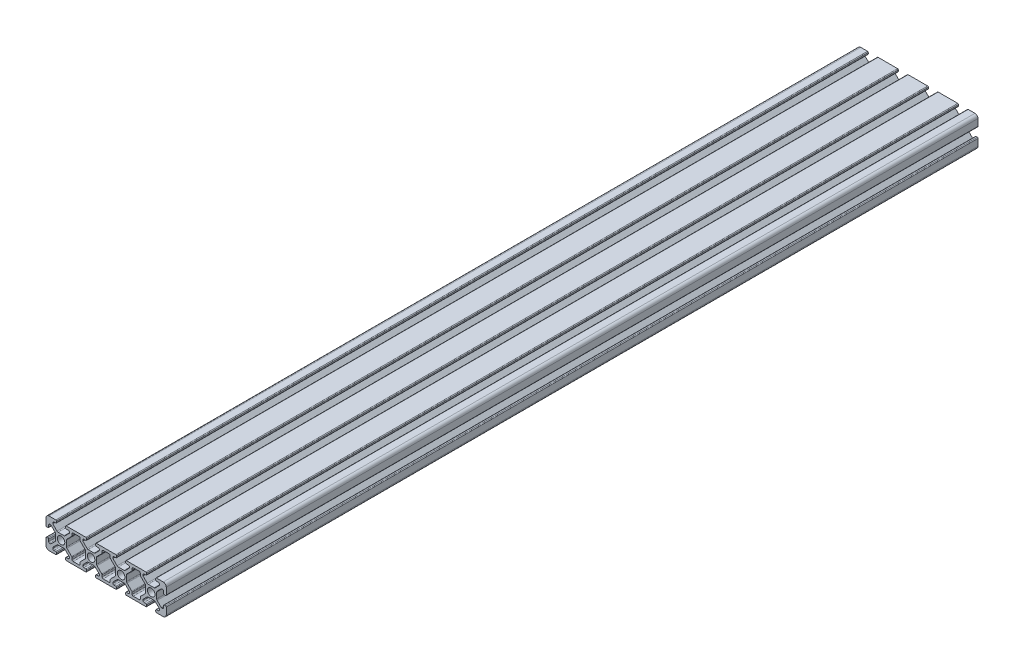
from build123d import *

# Parameters (mm, degrees)
SKETCH1_R           = 2.5
BOSS_EXTRUDE1_DEPTH = 270


with BuildPart() as part:
    # Sketch1 → Boss-Extrude1 (new body, symmetric)
    with BuildSketch(Plane.XY):
        with BuildLine():
            Line((2, 0), (6.5, 0))
            ThreePointArc((6.5, 0), (6.853553391, 0.146446609), (7, 0.5))
            Line((7, 0.5), (7, 1.3))
            ThreePointArc((7, 1.3), (6.853553391, 1.653553391), (6.5, 1.8))
            Line((6.5, 1.8), (5.25, 1.8))
            ThreePointArc((5.25, 1.8), (4.719669914, 2.019669914), (4.5, 2.55))
            Line((4.5, 2.55), (4.5, 3.227207794))
            Line((4.5, 3.227207794), (7.329898987, 6.057106781))
            ThreePointArc((7.329898987, 6.057106781), (7.654322336, 6.273879533), (8.037005769, 6.35))
            Line((8.037005769, 6.35), (11.962994231, 6.35))
            ThreePointArc((11.962994231, 6.35), (12.345677664, 6.273879533), (12.670101013, 6.057106781))
            Line((12.670101013, 6.057106781), (15.5, 3.227207794))
            Line((15.5, 3.227207794), (15.5, 2.55))
            ThreePointArc((15.5, 2.55), (15.280330086, 2.019669914), (14.75, 1.8))
            Line((14.75, 1.8), (13.5, 1.8))
            ThreePointArc((13.5, 1.8), (13.146446609, 1.653553391), (13, 1.3))
            Line((13, 1.3), (13, 0.5))
            ThreePointArc((13, 0.5), (13.146446609, 0.146446609), (13.5, 0))
            Line((13.5, 0), (26.5, 0))
            ThreePointArc((26.5, 0), (26.853553391, 0.146446609), (27, 0.5))
            Line((27, 0.5), (27, 1.3))
            ThreePointArc((27, 1.3), (26.853553391, 1.653553391), (26.5, 1.8))
            Line((26.5, 1.8), (25.25, 1.8))
            ThreePointArc((25.25, 1.8), (24.719669914, 2.019669914), (24.5, 2.55))
            Line((24.5, 2.55), (24.5, 3.227207794))
            Line((24.5, 3.227207794), (27.329898987, 6.057106781))
            ThreePointArc((27.329898987, 6.057106781), (27.654322336, 6.273879533), (28.037005769, 6.35))
            Line((28.037005769, 6.35), (31.962994231, 6.35))
            ThreePointArc((31.962994231, 6.35), (32.345677664, 6.273879533), (32.670101013, 6.057106781))
            Line((32.670101013, 6.057106781), (35.5, 3.227207794))
            Line((35.5, 3.227207794), (35.5, 2.55))
            ThreePointArc((35.5, 2.55), (35.280330086, 2.019669914), (34.75, 1.8))
            Line((34.75, 1.8), (33.5, 1.8))
            ThreePointArc((33.5, 1.8), (33.146446609, 1.653553391), (33, 1.3))
            Line((33, 1.3), (33, 0.5))
            ThreePointArc((33, 0.5), (33.146446609, 0.146446609), (33.5, 0))
            Line((33.5, 0), (46.5, 0))
            ThreePointArc((46.5, 0), (46.853553391, 0.146446609), (47, 0.5))
            Line((47, 0.5), (47, 1.3))
            ThreePointArc((47, 1.3), (46.853553391, 1.653553391), (46.5, 1.8))
            Line((46.5, 1.8), (45.25, 1.8))
            ThreePointArc((45.25, 1.8), (44.719669914, 2.019669914), (44.5, 2.55))
            Line((44.5, 2.55), (44.5, 3.227207794))
            Line((44.5, 3.227207794), (47.329898987, 6.057106781))
            ThreePointArc((47.329898987, 6.057106781), (47.654322336, 6.273879533), (48.037005769, 6.35))
            Line((48.037005769, 6.35), (51.962994231, 6.35))
            ThreePointArc((51.962994231, 6.35), (52.345677664, 6.273879533), (52.670101013, 6.057106781))
            Line((52.670101013, 6.057106781), (55.5, 3.227207794))
            Line((55.5, 3.227207794), (55.5, 2.55))
            ThreePointArc((55.5, 2.55), (55.280330086, 2.019669914), (54.75, 1.8))
            Line((54.75, 1.8), (53.5, 1.8))
            ThreePointArc((53.5, 1.8), (53.146446609, 1.653553391), (53, 1.3))
            Line((53, 1.3), (53, 0.5))
            ThreePointArc((53, 0.5), (53.146446609, 0.146446609), (53.5, 0))
            Line((53.5, 0), (66.5, 0))
            ThreePointArc((66.5, 0), (66.853553391, 0.146446609), (67, 0.5))
            Line((67, 0.5), (67, 1.3))
            ThreePointArc((67, 1.3), (66.853553391, 1.653553391), (66.5, 1.8))
            Line((66.5, 1.8), (65.25, 1.8))
            ThreePointArc((65.25, 1.8), (64.719669914, 2.019669914), (64.5, 2.55))
            Line((64.5, 2.55), (64.5, 3.227207794))
            Line((64.5, 3.227207794), (67.329898987, 6.057106781))
            ThreePointArc((67.329898987, 6.057106781), (67.654322336, 6.273879533), (68.037005769, 6.35))
            Line((68.037005769, 6.35), (71.962994231, 6.35))
            ThreePointArc((71.962994231, 6.35), (72.345677664, 6.273879533), (72.670101013, 6.057106781))
            Line((72.670101013, 6.057106781), (75.5, 3.227207794))
            Line((75.5, 3.227207794), (75.5, 2.55))
            ThreePointArc((75.5, 2.55), (75.280330086, 2.019669914), (74.75, 1.8))
            Line((74.75, 1.8), (73.5, 1.8))
            ThreePointArc((73.5, 1.8), (73.146446609, 1.653553391), (73, 1.3))
            Line((73, 1.3), (73, 0.5))
            ThreePointArc((73, 0.5), (73.146446609, 0.146446609), (73.5, 0))
            Line((73.5, 0), (78, 0))
            ThreePointArc((78, 0), (79.414213562, 0.585786438), (80, 2))
            Line((80, 2), (80, 6.5))
            ThreePointArc((80, 6.5), (79.853553391, 6.853553391), (79.5, 7))
            Line((79.5, 7), (78.7, 7))
            ThreePointArc((78.7, 7), (78.346446609, 6.853553391), (78.2, 6.5))
            Line((78.2, 6.5), (78.2, 5.25))
            ThreePointArc((78.2, 5.25), (77.980330086, 4.719669914), (77.45, 4.5))
            Line((77.45, 4.5), (76.772792206, 4.5))
            Line((76.772792206, 4.5), (73.942893219, 7.329898987))
            ThreePointArc((73.942893219, 7.329898987), (73.726120467, 7.654322336), (73.65, 8.037005769))
            Line((73.65, 8.037005769), (73.65, 11.962994231))
            ThreePointArc((73.65, 11.962994231), (73.726120467, 12.345677664), (73.942893219, 12.670101013))
            Line((73.942893219, 12.670101013), (76.772792206, 15.5))
            Line((76.772792206, 15.5), (77.45, 15.5))
            ThreePointArc((77.45, 15.5), (77.980330086, 15.280330086), (78.2, 14.75))
            Line((78.2, 14.75), (78.2, 13.5))
            ThreePointArc((78.2, 13.5), (78.346446609, 13.146446609), (78.7, 13))
            Line((78.7, 13), (79.5, 13))
            ThreePointArc((79.5, 13), (79.853553391, 13.146446609), (80, 13.5))
            Line((80, 13.5), (80, 18))
            ThreePointArc((80, 18), (79.414213562, 19.414213562), (78, 20))
            Line((78, 20), (73.5, 20))
            ThreePointArc((73.5, 20), (73.146446609, 19.853553391), (73, 19.5))
            Line((73, 19.5), (73, 18.7))
            ThreePointArc((73, 18.7), (73.146446609, 18.346446609), (73.5, 18.2))
            Line((73.5, 18.2), (74.75, 18.2))
            ThreePointArc((74.75, 18.2), (75.280330086, 17.980330086), (75.5, 17.45))
            Line((75.5, 17.45), (75.5, 16.772792206))
            Line((75.5, 16.772792206), (72.670101013, 13.942893219))
            ThreePointArc((72.670101013, 13.942893219), (72.345677664, 13.726120467), (71.962994231, 13.65))
            Line((71.962994231, 13.65), (68.037005769, 13.65))
            ThreePointArc((68.037005769, 13.65), (67.654322336, 13.726120467), (67.329898987, 13.942893219))
            Line((67.329898987, 13.942893219), (64.5, 16.772792206))
            Line((64.5, 16.772792206), (64.5, 17.45))
            ThreePointArc((64.5, 17.45), (64.719669914, 17.980330086), (65.25, 18.2))
            Line((65.25, 18.2), (66.5, 18.2))
            ThreePointArc((66.5, 18.2), (66.853553391, 18.346446609), (67, 18.7))
            Line((67, 18.7), (67, 19.5))
            ThreePointArc((67, 19.5), (66.853553391, 19.853553391), (66.5, 20))
            Line((66.5, 20), (53.5, 20))
            ThreePointArc((53.5, 20), (53.146446609, 19.853553391), (53, 19.5))
            Line((53, 19.5), (53, 18.7))
            ThreePointArc((53, 18.7), (53.146446609, 18.346446609), (53.5, 18.2))
            Line((53.5, 18.2), (54.75, 18.2))
            ThreePointArc((54.75, 18.2), (55.280330086, 17.980330086), (55.5, 17.45))
            Line((55.5, 17.45), (55.5, 16.772792206))
            Line((55.5, 16.772792206), (52.670101013, 13.942893219))
            ThreePointArc((52.670101013, 13.942893219), (52.345677664, 13.726120467), (51.962994231, 13.65))
            Line((51.962994231, 13.65), (48.037005769, 13.65))
            ThreePointArc((48.037005769, 13.65), (47.654322336, 13.726120467), (47.329898987, 13.942893219))
            Line((47.329898987, 13.942893219), (44.5, 16.772792206))
            Line((44.5, 16.772792206), (44.5, 17.45))
            ThreePointArc((44.5, 17.45), (44.719669914, 17.980330086), (45.25, 18.2))
            Line((45.25, 18.2), (46.5, 18.2))
            ThreePointArc((46.5, 18.2), (46.853553391, 18.346446609), (47, 18.7))
            Line((47, 18.7), (47, 19.5))
            ThreePointArc((47, 19.5), (46.853553391, 19.853553391), (46.5, 20))
            Line((46.5, 20), (33.5, 20))
            ThreePointArc((33.5, 20), (33.146446609, 19.853553391), (33, 19.5))
            Line((33, 19.5), (33, 18.7))
            ThreePointArc((33, 18.7), (33.146446609, 18.346446609), (33.5, 18.2))
            Line((33.5, 18.2), (34.75, 18.2))
            ThreePointArc((34.75, 18.2), (35.280330086, 17.980330086), (35.5, 17.45))
            Line((35.5, 17.45), (35.5, 16.772792206))
            Line((35.5, 16.772792206), (32.670101013, 13.942893219))
            ThreePointArc((32.670101013, 13.942893219), (32.345677664, 13.726120467), (31.962994231, 13.65))
            Line((31.962994231, 13.65), (28.037005769, 13.65))
            ThreePointArc((28.037005769, 13.65), (27.654322336, 13.726120467), (27.329898987, 13.942893219))
            Line((27.329898987, 13.942893219), (24.5, 16.772792206))
            Line((24.5, 16.772792206), (24.5, 17.45))
            ThreePointArc((24.5, 17.45), (24.719669914, 17.980330086), (25.25, 18.2))
            Line((25.25, 18.2), (26.5, 18.2))
            ThreePointArc((26.5, 18.2), (26.853553391, 18.346446609), (27, 18.7))
            Line((27, 18.7), (27, 19.5))
            ThreePointArc((27, 19.5), (26.853553391, 19.853553391), (26.5, 20))
            Line((26.5, 20), (13.5, 20))
            ThreePointArc((13.5, 20), (13.146446609, 19.853553391), (13, 19.5))
            Line((13, 19.5), (13, 18.7))
            ThreePointArc((13, 18.7), (13.146446609, 18.346446609), (13.5, 18.2))
            Line((13.5, 18.2), (14.75, 18.2))
            ThreePointArc((14.75, 18.2), (15.280330086, 17.980330086), (15.5, 17.45))
            Line((15.5, 17.45), (15.5, 16.772792206))
            Line((15.5, 16.772792206), (12.670101013, 13.942893219))
            ThreePointArc((12.670101013, 13.942893219), (12.345677664, 13.726120467), (11.962994231, 13.65))
            Line((11.962994231, 13.65), (8.037005769, 13.65))
            ThreePointArc((8.037005769, 13.65), (7.654322336, 13.726120467), (7.329898987, 13.942893219))
            Line((7.329898987, 13.942893219), (4.5, 16.772792206))
            Line((4.5, 16.772792206), (4.5, 17.45))
            ThreePointArc((4.5, 17.45), (4.719669914, 17.980330086), (5.25, 18.2))
            Line((5.25, 18.2), (6.5, 18.2))
            ThreePointArc((6.5, 18.2), (6.853553391, 18.346446609), (7, 18.7))
            Line((7, 18.7), (7, 19.5))
            ThreePointArc((7, 19.5), (6.853553391, 19.853553391), (6.5, 20))
            Line((6.5, 20), (2, 20))
            ThreePointArc((2, 20), (0.585786438, 19.414213562), (0, 18))
            Line((0, 18), (0, 13.5))
            ThreePointArc((0, 13.5), (0.146446609, 13.146446609), (0.5, 13))
            Line((0.5, 13), (1.3, 13))
            ThreePointArc((1.3, 13), (1.653553391, 13.146446609), (1.8, 13.5))
            Line((1.8, 13.5), (1.8, 14.75))
            ThreePointArc((1.8, 14.75), (2.019669914, 15.280330086), (2.55, 15.5))
            Line((2.55, 15.5), (3.227207794, 15.5))
            Line((3.227207794, 15.5), (6.057106781, 12.670101013))
            ThreePointArc((6.057106781, 12.670101013), (6.273879533, 12.345677664), (6.35, 11.962994231))
            Line((6.35, 11.962994231), (6.35, 8.037005769))
            ThreePointArc((6.35, 8.037005769), (6.273879533, 7.654322336), (6.057106781, 7.329898987))
            Line((6.057106781, 7.329898987), (3.227207794, 4.5))
            Line((3.227207794, 4.5), (2.55, 4.5))
            ThreePointArc((2.55, 4.5), (2.019669914, 4.719669914), (1.8, 5.25))
            Line((1.8, 5.25), (1.8, 6.5))
            ThreePointArc((1.8, 6.5), (1.653553391, 6.853553391), (1.3, 7))
            Line((1.3, 7), (0.5, 7))
            ThreePointArc((0.5, 7), (0.146446609, 6.853553391), (0, 6.5))
            Line((0, 6.5), (0, 2))
            ThreePointArc((0, 2), (0.585786438, 0.585786438), (2, 0))
        make_face()
        with Locations((10, 10)):
            Circle(SKETCH1_R, mode=Mode.SUBTRACT)
        with Locations((30, 10)):
            Circle(SKETCH1_R, mode=Mode.SUBTRACT)
        with Locations((50, 10)):
            Circle(SKETCH1_R, mode=Mode.SUBTRACT)
        with Locations((70, 10)):
            Circle(SKETCH1_R, mode=Mode.SUBTRACT)
        with BuildLine():
            Line((33.942893219, 12.670101013), (37.080330086, 15.80753788))
            ThreePointArc((37.080330086, 15.80753788), (37.242909649, 16.050855391), (37.3, 16.337867966))
            Line((37.3, 16.337867966), (37.3, 17.45))
            ThreePointArc((37.3, 17.45), (37.519669914, 17.980330086), (38.05, 18.2))
            Line((38.05, 18.2), (41.95, 18.2))
            ThreePointArc((41.95, 18.2), (42.480330086, 17.980330086), (42.7, 17.45))
            Line((42.7, 17.45), (42.7, 16.337867966))
            ThreePointArc((42.7, 16.337867966), (42.757090351, 16.050855391), (42.919669914, 15.80753788))
            Line((42.919669914, 15.80753788), (46.057106781, 12.670101013))
            ThreePointArc((46.057106781, 12.670101013), (46.273879533, 12.345677664), (46.35, 11.962994231))
            Line((46.35, 11.962994231), (46.35, 8.037005769))
            ThreePointArc((46.35, 8.037005769), (46.273879533, 7.654322336), (46.057106781, 7.329898987))
            Line((46.057106781, 7.329898987), (42.919669914, 4.19246212))
            ThreePointArc((42.919669914, 4.19246212), (42.757090351, 3.949144609), (42.7, 3.662132034))
            Line((42.7, 3.662132034), (42.7, 2.55))
            ThreePointArc((42.7, 2.55), (42.480330086, 2.019669914), (41.95, 1.8))
            Line((41.95, 1.8), (38.05, 1.8))
            ThreePointArc((38.05, 1.8), (37.519669914, 2.019669914), (37.3, 2.55))
            Line((37.3, 2.55), (37.3, 3.662132034))
            ThreePointArc((37.3, 3.662132034), (37.242909649, 3.949144609), (37.080330086, 4.19246212))
            Line((37.080330086, 4.19246212), (33.942893219, 7.329898987))
            ThreePointArc((33.942893219, 7.329898987), (33.726120467, 7.654322336), (33.65, 8.037005769))
            Line((33.65, 8.037005769), (33.65, 11.962994231))
            ThreePointArc((33.65, 11.962994231), (33.726120467, 12.345677664), (33.942893219, 12.670101013))
        make_face(mode=Mode.SUBTRACT)
        with BuildLine():
            Line((22.919669914, 15.80753788), (26.057106781, 12.670101013))
            ThreePointArc((26.057106781, 12.670101013), (26.273879533, 12.345677664), (26.35, 11.962994231))
            Line((26.35, 11.962994231), (26.35, 8.037005769))
            ThreePointArc((26.35, 8.037005769), (26.273879533, 7.654322336), (26.057106781, 7.329898987))
            Line((26.057106781, 7.329898987), (22.919669914, 4.19246212))
            ThreePointArc((22.919669914, 4.19246212), (22.757090351, 3.949144609), (22.7, 3.662132034))
            Line((22.7, 3.662132034), (22.7, 2.55))
            ThreePointArc((22.7, 2.55), (22.480330086, 2.019669914), (21.95, 1.8))
            Line((21.95, 1.8), (18.05, 1.8))
            ThreePointArc((18.05, 1.8), (17.519669914, 2.019669914), (17.3, 2.55))
            Line((17.3, 2.55), (17.3, 3.662132034))
            ThreePointArc((17.3, 3.662132034), (17.242909649, 3.949144609), (17.080330086, 4.19246212))
            Line((17.080330086, 4.19246212), (13.942893219, 7.329898987))
            ThreePointArc((13.942893219, 7.329898987), (13.726120467, 7.654322336), (13.65, 8.037005769))
            Line((13.65, 8.037005769), (13.65, 11.962994231))
            ThreePointArc((13.65, 11.962994231), (13.726120467, 12.345677664), (13.942893219, 12.670101013))
            Line((13.942893219, 12.670101013), (17.080330086, 15.80753788))
            ThreePointArc((17.080330086, 15.80753788), (17.242909649, 16.050855391), (17.3, 16.337867966))
            Line((17.3, 16.337867966), (17.3, 17.45))
            ThreePointArc((17.3, 17.45), (17.519669914, 17.980330086), (18.05, 18.2))
            Line((18.05, 18.2), (21.95, 18.2))
            ThreePointArc((21.95, 18.2), (22.480330086, 17.980330086), (22.7, 17.45))
            Line((22.7, 17.45), (22.7, 16.337867966))
            ThreePointArc((22.7, 16.337867966), (22.757090351, 16.050855391), (22.919669914, 15.80753788))
        make_face(mode=Mode.SUBTRACT)
        with BuildLine():
            Line((62.919669914, 15.80753788), (66.057106781, 12.670101013))
            ThreePointArc((66.057106781, 12.670101013), (66.273879533, 12.345677664), (66.35, 11.962994231))
            Line((66.35, 11.962994231), (66.35, 8.037005769))
            ThreePointArc((66.35, 8.037005769), (66.273879533, 7.654322336), (66.057106781, 7.329898987))
            Line((66.057106781, 7.329898987), (62.919669914, 4.19246212))
            ThreePointArc((62.919669914, 4.19246212), (62.757090351, 3.949144609), (62.7, 3.662132034))
            Line((62.7, 3.662132034), (62.7, 2.55))
            ThreePointArc((62.7, 2.55), (62.480330086, 2.019669914), (61.95, 1.8))
            Line((61.95, 1.8), (58.05, 1.8))
            ThreePointArc((58.05, 1.8), (57.519669914, 2.019669914), (57.3, 2.55))
            Line((57.3, 2.55), (57.3, 3.662132034))
            ThreePointArc((57.3, 3.662132034), (57.242909649, 3.949144609), (57.080330086, 4.19246212))
            Line((57.080330086, 4.19246212), (53.942893219, 7.329898987))
            ThreePointArc((53.942893219, 7.329898987), (53.726120467, 7.654322336), (53.65, 8.037005769))
            Line((53.65, 8.037005769), (53.65, 11.962994231))
            ThreePointArc((53.65, 11.962994231), (53.726120467, 12.345677664), (53.942893219, 12.670101013))
            Line((53.942893219, 12.670101013), (57.080330086, 15.80753788))
            ThreePointArc((57.080330086, 15.80753788), (57.242909649, 16.050855391), (57.3, 16.337867966))
            Line((57.3, 16.337867966), (57.3, 17.45))
            ThreePointArc((57.3, 17.45), (57.519669914, 17.980330086), (58.05, 18.2))
            Line((58.05, 18.2), (61.95, 18.2))
            ThreePointArc((61.95, 18.2), (62.480330086, 17.980330086), (62.7, 17.45))
            Line((62.7, 17.45), (62.7, 16.337867966))
            ThreePointArc((62.7, 16.337867966), (62.757090351, 16.050855391), (62.919669914, 15.80753788))
        make_face(mode=Mode.SUBTRACT)
    extrude(amount=BOSS_EXTRUDE1_DEPTH, both=True)


solid = part.part
